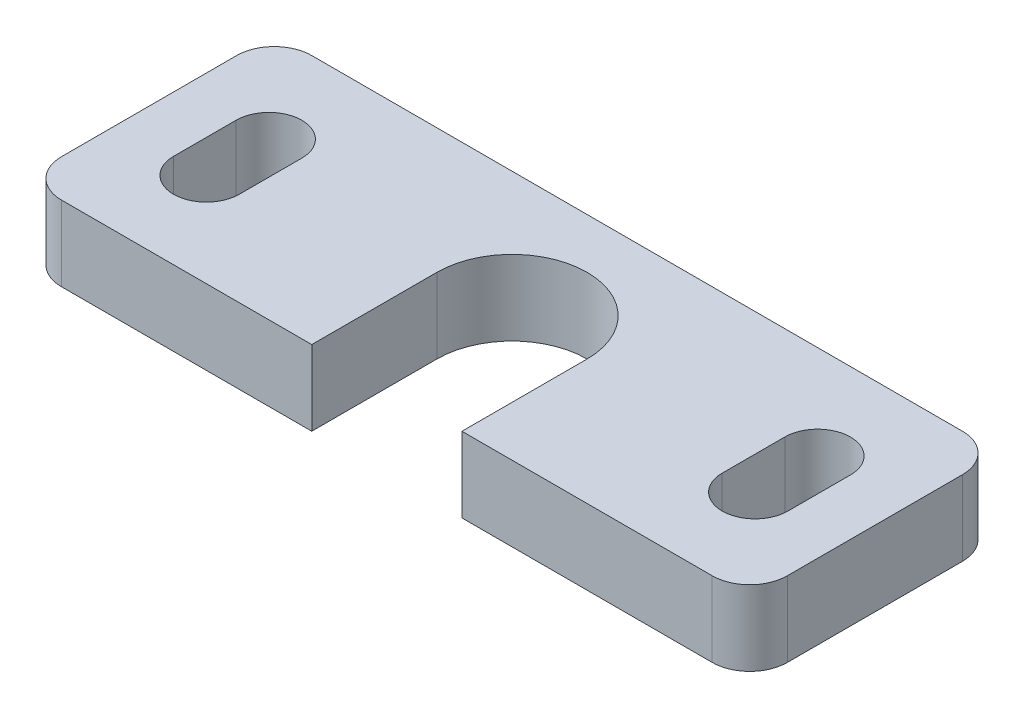
from build123d import *

# Parameters (mm, degrees)
BOSS_EXTRUDE1_DEPTH = 6
FILLET1_R           = 3


with BuildPart() as part:
    # Sketch1 → Boss-Extrude1 (new body)
    with BuildSketch(Plane(origin=(0, 0, 0), x_dir=(1, 0, 0), z_dir=(0, 1, 0))):
        with BuildLine():
            Line((0, 0), (23, 0))
            Line((23, 0), (23, 10))
            ThreePointArc((23, 10), (29, 16), (35, 10))
            Line((35, 10), (35, 0))
            Line((35, 0), (58, 0))
            Line((58, 0), (58, 20))
            Line((58, 20), (0, 20))
            Line((0, 20), (0, 0))
        make_face()
        with BuildLine():
            Line((9.705, 12.5), (9.705, 7.5))
            ThreePointArc((9.705, 7.5), (7.08, 4.875), (4.455, 7.5))
            Line((4.455, 7.5), (4.455, 12.5))
            ThreePointArc((4.455, 12.5), (7.08, 15.125), (9.705, 12.5))
        make_face(mode=Mode.SUBTRACT)
        with BuildLine():
            Line((48.295, 12.5), (48.295, 7.5))
            ThreePointArc((48.295, 7.5), (50.92, 4.875), (53.545, 7.5))
            Line((53.545, 7.5), (53.545, 12.5))
            ThreePointArc((53.545, 12.5), (50.92, 15.125), (48.295, 12.5))
        make_face(mode=Mode.SUBTRACT)
    extrude(amount=BOSS_EXTRUDE1_DEPTH)

    # Fillet1
    fillet1_edges = [part.edges().sort_by_distance(p)[0] for p in [
        (0, 3, -20),
        (58, 3, -20),
        (58, 3, 0),
        (0, 3, 0),
    ]]
    fillet(fillet1_edges, radius=FILLET1_R)


solid = part.part
